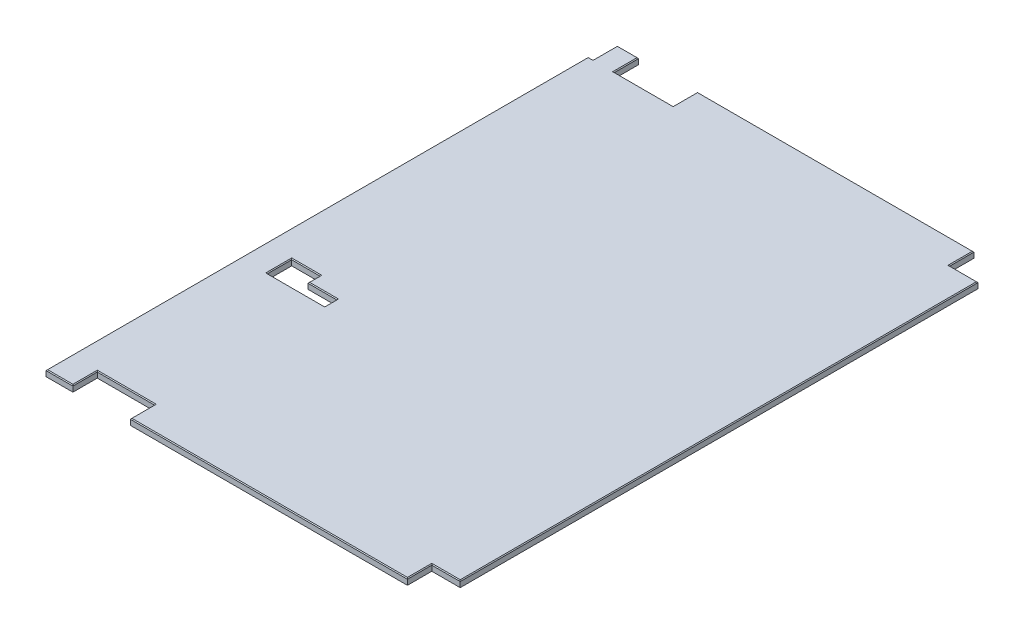
from build123d import *

# Parameters (mm, degrees)
SKETCH1_W           = 1219.2
SKETCH1_H           = 1771.65
BOSS_EXTRUDE1_DEPTH = 9.525
SKETCH3_W           = 184.1373
SKETCH3_H           = 76.2
SKETCH3_W_2         = 88.9
SKETCH3_W_3         = 179.3875
SKETCH3_W_4         = 15.2273
CUT_EXTRUDE2_DEPTH  = 20.05
CHAMFER1_SIZE       = 2.54


with BuildPart() as part:
    # Sketch1 → Boss-Extrude1 (new body, symmetric)
    with BuildSketch(Plane(origin=(0, 0, 0), x_dir=(1, 0, 0), z_dir=(0, 1, 0))):
        with Locations((609.6, 885.825)):
            Rectangle(SKETCH1_W, SKETCH1_H)
    extrude(amount=BOSS_EXTRUDE1_DEPTH, both=True)

    # Sketch3 → Cut-Extrude2 (cut, through all)
    with BuildSketch(Plane(origin=(0, 9.525, 0), x_dir=(1, 0, 0), z_dir=(0, 1, 0))):
        with Locations((173.78045, 1733.55)):
            Rectangle(SKETCH3_W, SKETCH3_H)
        with Locations((1174.75, 1733.55)):
            Rectangle(SKETCH3_W_2, SKETCH3_H)
        Polygon((84.1756, 684.212499999), (173.167165563, 684.212499999), (173.167165563, 646.125199999), (263.5631, 646.125199999), (263.5631, 608.012499999), (84.1756, 608.012499999), align=None)
        with Locations((173.86935, 38.1)):
            Rectangle(SKETCH3_W_3, SKETCH3_H)
        with Locations((1174.75, 38.1)):
            Rectangle(SKETCH3_W_2, SKETCH3_H)
        with Locations((7.61365, 1733.55)):
            Rectangle(SKETCH3_W_4, SKETCH3_H)
    extrude(amount=-CUT_EXTRUDE2_DEPTH, mode=Mode.SUBTRACT)

    # Chamfer1
    chamfer1_edges = [part.edges().sort_by_distance(p)[0] for p in [
        (0, 9.525, -847.725),
        (696.93155, 9.525, 0),
        (1219.2, 9.525, -885.825),
        (698.07455, 9.525, -1771.65),
        (48.46955, 9.525, -1771.65),
        (7.61365, 9.525, -1695.45),
        (15.2273, 9.525, -1733.55),
        (1174.75, 9.525, -76.2),
        (1130.3, 9.525, -38.1),
        (263.5631, 9.525, -38.1),
        (173.86935, 9.525, -76.2),
        (84.1756, 9.525, -38.1),
        (84.1756, 9.525, -646.112499999),
        (173.86935, 9.525, -608.012499999),
        (263.5631, 9.525, -627.068849999),
        (218.365132782, 9.525, -646.125199999),
        (173.167165563, 9.525, -665.168849999),
        (128.671382782, 9.525, -684.212499999),
        (1130.3, 9.525, -1733.55),
        (1174.75, 9.525, -1695.45),
        (81.7118, 9.525, -1733.55),
        (173.78045, 9.525, -1695.45),
        (265.8491, 9.525, -1733.55),
        (42.0878, 9.525, 0),
    ]]
    chamfer(chamfer1_edges, length=CHAMFER1_SIZE)


solid = part.part
